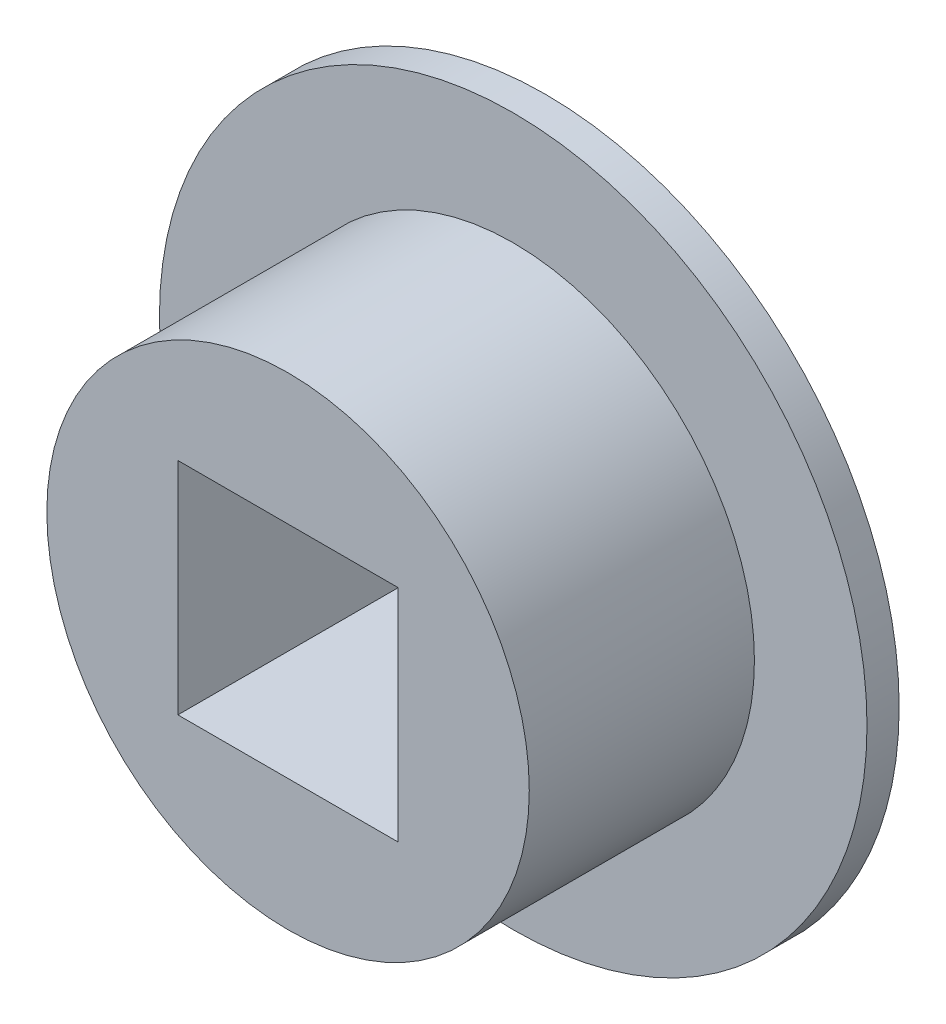
from build123d import *

# Parameters (mm, degrees)
SKETCH1_R           = 7.5
SKETCH1_W           = 6.85
SKETCH1_H           = 6.85
BOSS_EXTRUDE1_DEPTH = 4
BOSS_EXTRUDE2_START = -1
SKETCH2_R           = 11
SKETCH2_R_2         = 7.5
BOSS_EXTRUDE2_DEPTH = 1


with BuildPart() as part:
    # Sketch1 → Boss-Extrude1 (new, symmetric)
    with BuildSketch(Plane.XY):
        Circle(SKETCH1_R)
        Rectangle(SKETCH1_W, SKETCH1_H, mode=Mode.SUBTRACT)
    extrude(amount=BOSS_EXTRUDE1_DEPTH, both=True)

    # Sketch2 → Boss-Extrude2 (add)
    with BuildSketch(Plane(origin=(0, 0, -4), x_dir=(-1, 0, 0), z_dir=(0, 0, -1)).offset(BOSS_EXTRUDE2_START)):
        Circle(SKETCH2_R)
        Circle(SKETCH2_R_2, mode=Mode.SUBTRACT)
    extrude(amount=BOSS_EXTRUDE2_DEPTH)


solid = part.part
